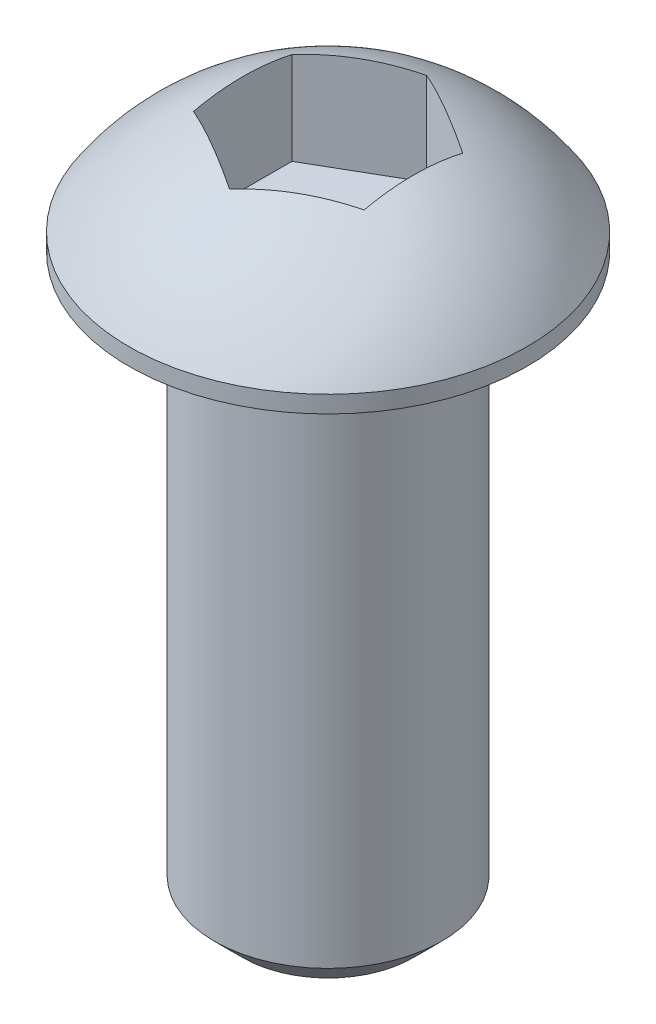
from build123d import *

# Parameters (mm, degrees)
SKETCH1_R           = 2
BOSS_EXTRUDE3_DEPTH = 10
CHAMFER2_SIZE       = 0.5
CUT_EXTRUDE2_DEPTH  = 2


with BuildPart() as part:
    # Sketch1 → Boss-Extrude3 (new body)
    with BuildSketch(Plane(origin=(0, 0, 0), x_dir=(1, 0, 0), z_dir=(0, 1, 0))):
        Circle(SKETCH1_R)
    extrude(amount=-BOSS_EXTRUDE3_DEPTH)

    # Sketch3 → Revolve2 (revolve)
    with BuildSketch(Plane.XY):
        with BuildLine():
            Line((-3.5, 0), (-3.5, 0.3))
            ThreePointArc((-3.5, 0.3), (-1.988393808, 1.6859585), (0, 2.188078318))
            Line((0, 2.188078318), (0, 0))
            Line((0, 0), (-3.5, 0))
        make_face()
    revolve(axis=Axis((0, -2, 0), (0, 1, 0)))

    # Chamfer2
    chamfer2_edges = [part.edges().sort_by_distance(p)[0] for p in [
        (-2, -10, 0),
    ]]
    chamfer(chamfer2_edges, length=CHAMFER2_SIZE)

    # Sketch4 → Cut-Extrude2 (cut)
    with BuildSketch(Plane(origin=(0, 2.188078318, 0), x_dir=(1, 0, 0), z_dir=(0, 1, 0))):
        Polygon((0, 1.732050808), (-1.5, 0.866025404), (-1.5, -0.866025404), (0, -1.732050808), (1.5, -0.866025404), (1.5, 0.866025404), align=None)
    extrude(amount=-CUT_EXTRUDE2_DEPTH, mode=Mode.SUBTRACT)


solid = part.part
